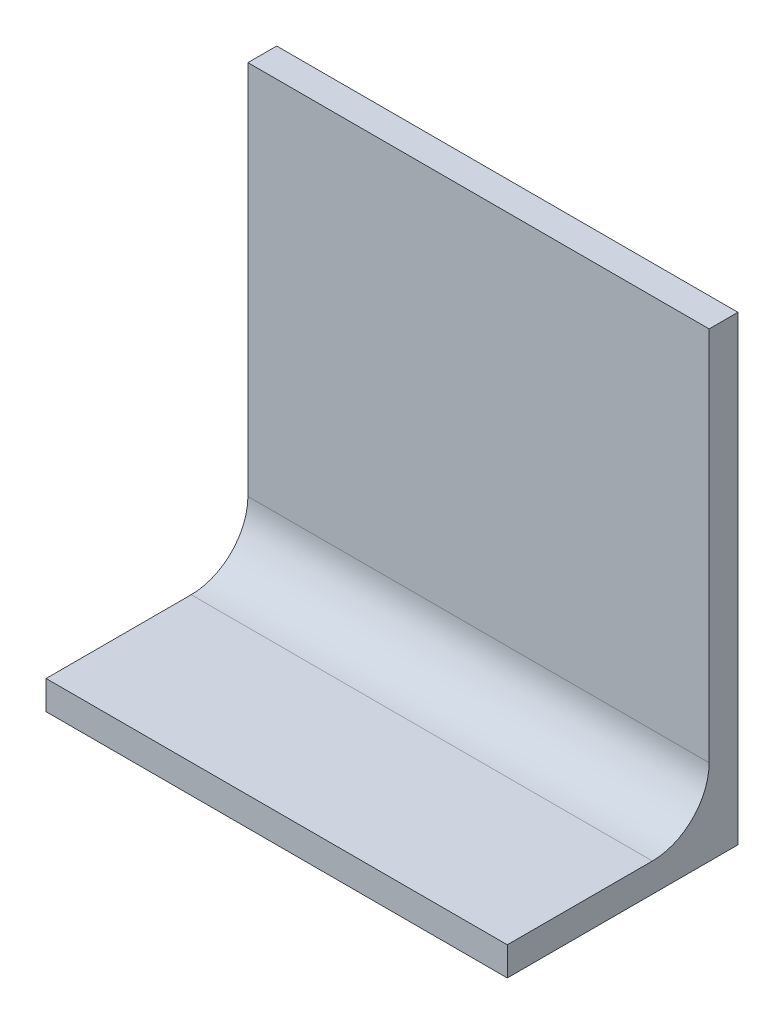
from build123d import *

# Parameters (mm, degrees)
BOSS_EXTRUDE1_DEPTH = 25.4
FILLET1_R           = 6.25


with BuildPart() as part:
    # Sketch1 → Boss-Extrude1 (new body, symmetric)
    with BuildSketch(Plane(origin=(0, 0, 0), x_dir=(0, 0, -1), z_dir=(1, 0, 0))):
        Polygon((0, 0), (22.23, 0), (22.23, 47.63), (25.4, 47.63), (25.4, -3.17), (0, -3.17), align=None)
    extrude(amount=BOSS_EXTRUDE1_DEPTH, both=True)

    # Fillet1
    fillet1_edges = [part.edges().sort_by_distance(p)[0] for p in [
        (0, 0, -22.23),
    ]]
    fillet(fillet1_edges, radius=FILLET1_R)


solid = part.part
